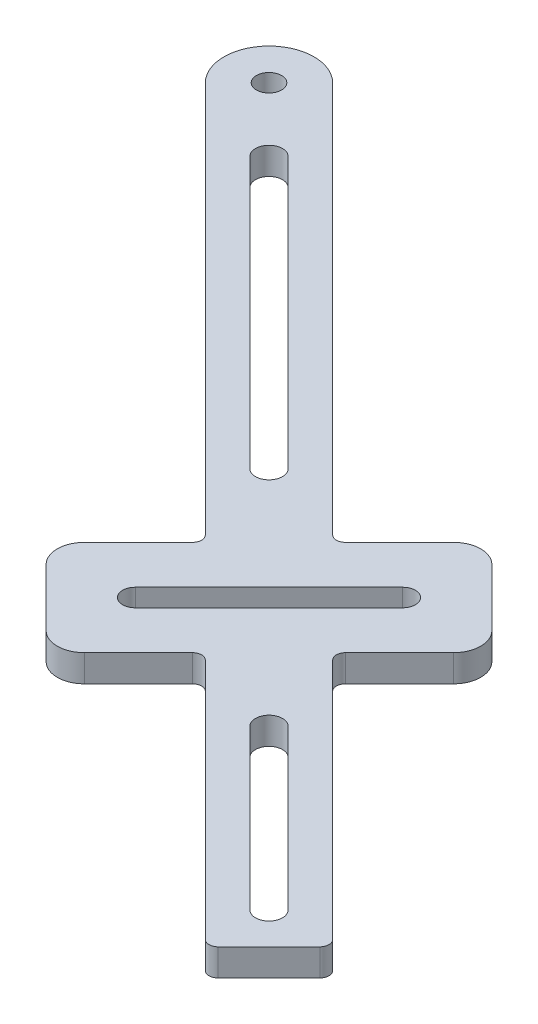
from build123d import *

# Parameters (mm, degrees)
SKETCH1_R           = 1.4
BOSS_EXTRUDE1_DEPTH = 3


with BuildPart() as part:
    # Sketch1 → Boss-Extrude1 (new body)
    with BuildSketch(Plane(origin=(0, 0, 0), x_dir=(1, 0, 0), z_dir=(0, 1, 0))):
        with BuildLine():
            Line((66.715956662, -50.018199395), (23.228889619, -6.531132352))
            ThreePointArc((23.228889619, -6.531132352), (16.157821807, -6.531132352), (16.157821807, -13.602200164))
            Line((16.157821807, -13.602200164), (59.64488885, -57.089267207))
            ThreePointArc((59.64488885, -57.089267207), (59.937782069, -57.796373988), (59.64488885, -58.503480769))
            Line((59.64488885, -58.503480769), (53.63448121, -64.513888409))
            ThreePointArc((53.63448121, -64.513888409), (52.755801554, -66.635208753), (53.63448121, -68.756529097))
            Line((53.63448121, -68.756529097), (59.998442241, -75.120490127))
            ThreePointArc((59.998442241, -75.120490127), (62.119762584, -75.999169784), (64.241082928, -75.120490127))
            Line((64.241082928, -75.120490127), (70.251490568, -69.110082487))
            ThreePointArc((70.251490568, -69.110082487), (70.958597349, -68.817189268), (71.665704131, -69.110082487))
            Line((71.665704131, -69.110082487), (98.535761816, -95.980140172))
            ThreePointArc((98.535761816, -95.980140172), (99.242868597, -96.273033391), (99.949975378, -95.980140172))
            Line((99.949975378, -95.980140172), (105.606829627, -90.323285923))
            ThreePointArc((105.606829627, -90.323285923), (105.899722846, -89.616179142), (105.606829627, -88.90907236))
            Line((105.606829627, -88.90907236), (78.736771942, -62.039014675))
            ThreePointArc((78.736771942, -62.039014675), (78.443878724, -61.331907894), (78.736771942, -60.624801113))
            Line((78.736771942, -60.624801113), (84.747179582, -54.614393473))
            ThreePointArc((84.747179582, -54.614393473), (85.625859239, -52.493073129), (84.747179582, -50.371752786))
            Line((84.747179582, -50.371752786), (78.383218552, -44.007791755))
            ThreePointArc((78.383218552, -44.007791755), (76.261898208, -43.129112099), (74.140577865, -44.007791755))
            Line((74.140577865, -44.007791755), (68.130170225, -50.018199395))
            ThreePointArc((68.130170225, -50.018199395), (67.423063443, -50.311092614), (66.715956662, -50.018199395))
        make_face()
        with Locations((19.693355713, -10.066666258)):
            Circle(SKETCH1_R, mode=Mode.SUBTRACT)
        with BuildLine():
            Line((82.625859239, -70.87784944), (100.303528769, -88.55551897))
            ThreePointArc((100.303528769, -88.55551897), (100.303528769, -90.676839313), (98.182208425, -90.676839313))
            Line((98.182208425, -90.676839313), (80.504538895, -72.999169784))
            ThreePointArc((80.504538895, -72.999169784), (80.504538895, -70.87784944), (82.625859239, -70.87784944))
        make_face(mode=Mode.SUBTRACT)
        with BuildLine():
            Line((60.7762597, -65.99881265), (75.625502105, -51.149570245))
            ThreePointArc((75.625502105, -51.149570245), (77.605401092, -51.149570245), (77.605401092, -53.129469232))
            Line((77.605401092, -53.129469232), (62.756158688, -67.978711637))
            ThreePointArc((62.756158688, -67.978711637), (60.7762597, -67.978711637), (60.7762597, -65.99881265))
        make_face(mode=Mode.SUBTRACT)
        with BuildLine():
            Line((27.825083697, -16.077073898), (57.877121897, -46.129112099))
            ThreePointArc((57.877121897, -46.129112099), (57.877121897, -48.250432442), (55.755801554, -48.250432442))
            Line((55.755801554, -48.250432442), (25.703763353, -18.198394242))
            ThreePointArc((25.703763353, -18.198394242), (25.703763353, -16.077073898), (27.825083697, -16.077073898))
        make_face(mode=Mode.SUBTRACT)
    extrude(amount=BOSS_EXTRUDE1_DEPTH)


solid = part.part
